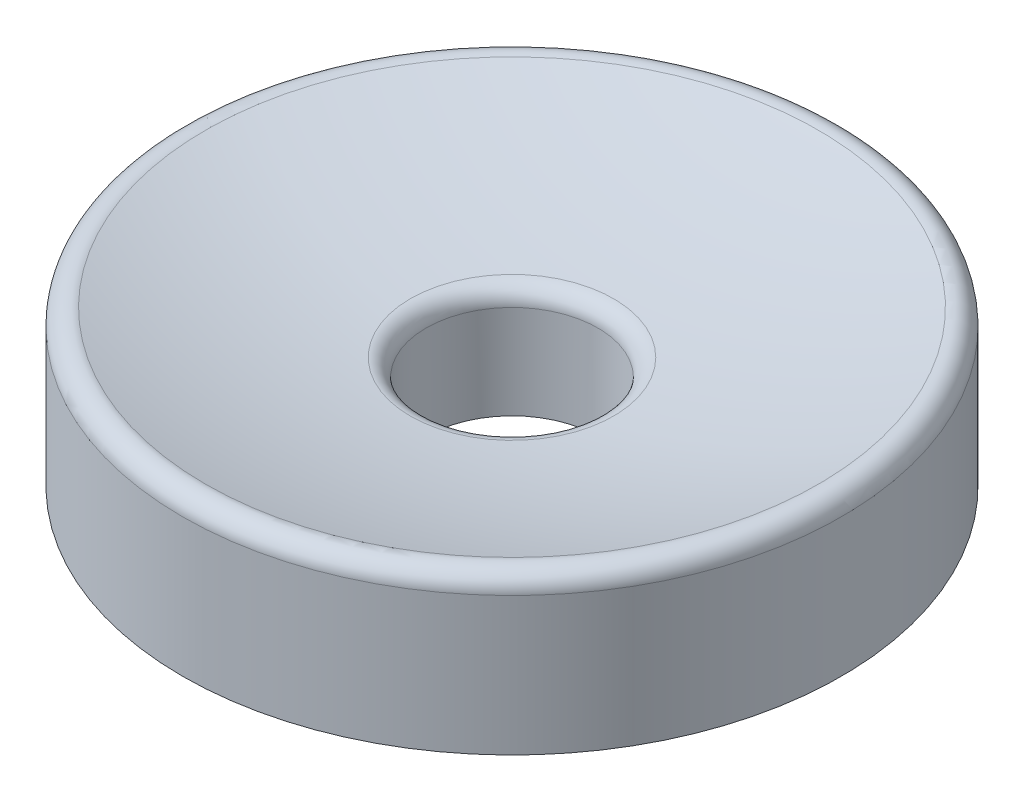
from build123d import *

# Parameters (mm, degrees)
FILLET1_R = 1.016
FILLET2_R = 1.016


with BuildPart() as part:
    # Sketch1 → Revolve1 (revolve)
    with BuildSketch(Plane.XY, mode=Mode.PRIVATE) as revolve1_sk:
        with BuildLine():
            Line((4.9657, -63.283859201), (19.05, -63.283859201))
            Line((19.05, -63.283859201), (19.05, -53.881536726))
            ThreePointArc((19.05, -53.881536726), (12.104446693, -55.853423084), (4.9657, -56.933859201))
            Line((4.9657, -56.933859201), (4.9657, -63.283859201))
        make_face()
    revolve(revolve1_sk.sketch.rotate(Axis((0, 0, 0), (0, -1, 0)), 90), axis=Axis((0, 0, 0), (0, -1, 0)))  # turned: the seam where the file's is

    # Fillet1
    fillet1_edges = [part.edges().sort_by_distance(p)[0] for p in [
        (0, -53.881536726, -19.05),
    ]]
    fillet(fillet1_edges, radius=FILLET1_R)

    # Fillet2
    fillet2_edges = [part.edges().sort_by_distance(p)[0] for p in [
        (0, -56.933859201, -4.9657),
    ]]
    fillet(fillet2_edges, radius=FILLET2_R)


solid = part.part
